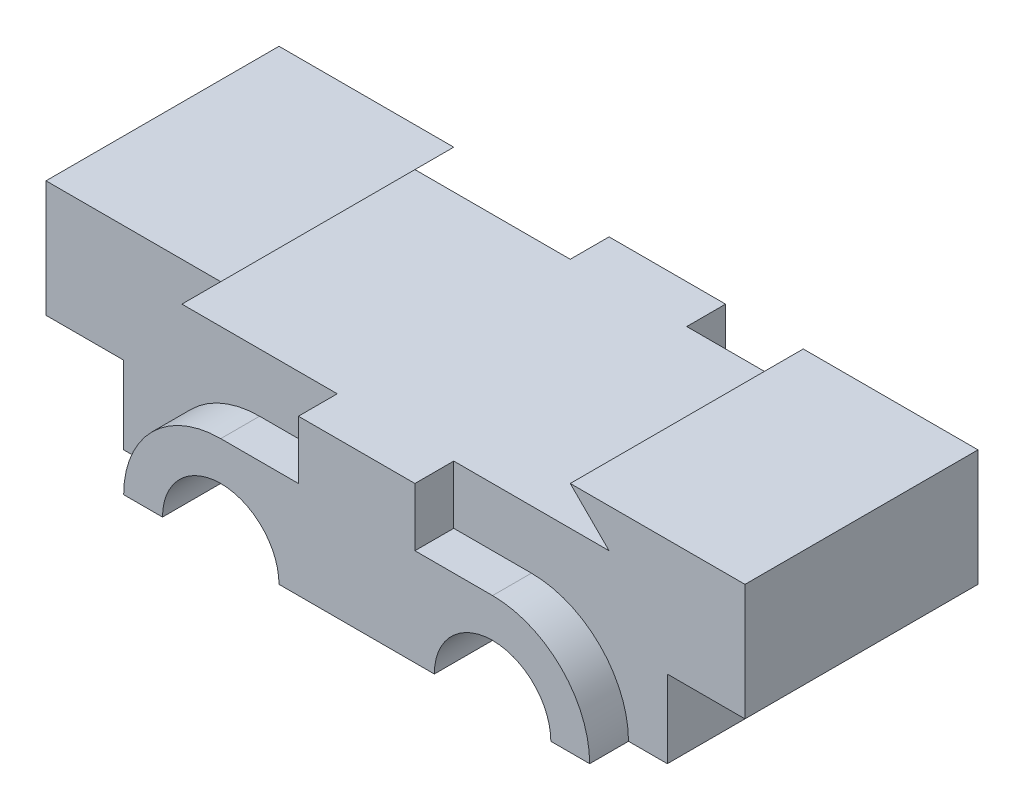
from build123d import *

# Parameters (mm, degrees)
BOSS_EXTRUDE1_DEPTH = 5
BOSS_EXTRUDE2_DEPTH = 15
CUT_EXTRUDE1_DEPTH  = 15
SKETCH7_R           = 2.25
CUT_EXTRUDE2_DEPTH  = 15


with BuildPart() as part:
    # Sketch1 → Boss-Extrude1 (new body)
    with BuildSketch(Plane.XY):
        with BuildLine():
            Line((-17.5, 12.5), (-7.5, 12.5))
            Line((-7.5, 12.5), (-7.5, 20))
            Line((-7.5, 20), (7.5, 20))
            Line((7.5, 20), (7.5, 12.5))
            Line((7.5, 12.5), (17.5, 12.5))
            ThreePointArc((17.5, 12.5), (26.338834765, 8.838834765), (30, 0))
            Line((30, 0), (25, 0))
            ThreePointArc((25, 0), (17.5, 7.5), (10, 0))
            Line((10, 0), (-10, 0))
            ThreePointArc((-10, 0), (-17.5, 7.5), (-25, 0))
            Line((-25, 0), (-30, 0))
            ThreePointArc((-30, 0), (-26.338834765, 8.838834765), (-17.5, 12.5))
        make_face()
    extrude(amount=BOSS_EXTRUDE1_DEPTH)

    # Sketch4 → Boss-Extrude2 (add)
    with BuildSketch(Plane(origin=(0, 0, 0), x_dir=(-1, 0, 0), z_dir=(0, 0, -1))):
        Polygon((35, 0), (-35, 0), (-35, 10), (-45, 10), (-45, 25), (-22.5, 25), (-27.5, 20), (27.5, 20), (22.5, 25), (45, 25), (45, 10), (35, 10), align=None)
    extrude(amount=BOSS_EXTRUDE2_DEPTH)

    # Sketch6 → Cut-Extrude1 (cut)
    with BuildSketch(Plane.XY):
        with BuildLine():
            Line((10, 0), (25, 0))
            ThreePointArc((25, 0), (17.5, 7.5), (10, 0))
        make_face()
        with BuildLine():
            Line((-25, 0), (-10, 0))
            ThreePointArc((-10, 0), (-17.5, 7.5), (-25, 0))
        make_face()
    extrude(amount=-CUT_EXTRUDE1_DEPTH, mode=Mode.SUBTRACT)

    # Sketch7 → Cut-Extrude2 (cut)
    with BuildSketch(Plane(origin=(0, 0, 0), x_dir=(1, 0, 0), z_dir=(0, 1, 0))):
        Circle(SKETCH7_R)
        with Locations((-30, 7.5)):
            Circle(SKETCH7_R)
        with Locations((30, 7.5)):
            Circle(SKETCH7_R)
    extrude(amount=CUT_EXTRUDE2_DEPTH, mode=Mode.SUBTRACT)

    # Mirror2: part across plane


with BuildPart() as part_1:
    add(part.part)
    add(part.part.mirror(Plane(origin=(0, 0, -15), x_dir=(1, 0, 0), z_dir=(0, 0, -1))))


solid = part_1.part
